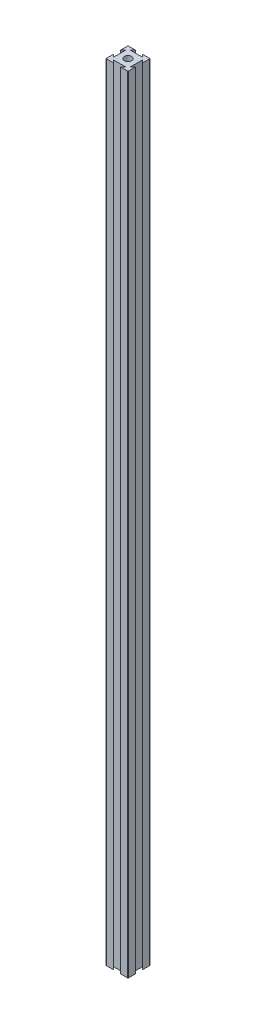
from build123d import *

# Parameters (mm, degrees)
SKETCH1_R           = 3.333333333
BOSS_EXTRUDE1_DEPTH = 711.2
FILLET4_R           = 0.508


with BuildPart() as part:
    # Sketch1 → Boss-Extrude1 (new body)
    with BuildSketch(Plane(origin=(0, 0, 0), x_dir=(1, 0, 0), z_dir=(0, 1, 0))):
        Polygon((4.285, 17.618333333), (6.666666667, 20), (0, 20), (0, 13.333333333), (2.381666667, 15.715), (2.381666667, 4.285), (0, 6.666666667), (0, 0), (6.666666667, 0), (4.285, 2.381666667), (15.715, 2.381666667), (13.333333333, 0), (20, 0), (20, 6.666666667), (17.618333333, 4.285), (17.618333333, 15.715), (20, 13.333333333), (20, 20), (13.333333333, 20), (15.715, 17.618333333), align=None)
        with Locations((10, 10)):
            Circle(SKETCH1_R, mode=Mode.SUBTRACT)
    extrude(amount=BOSS_EXTRUDE1_DEPTH)

    # Fillet4
    fillet4_edges = [part.edges().sort_by_distance(p)[0] for p in [
        (20, 355.6, 0),
        (0, 355.6, 0),
        (0, 355.6, -20),
        (20, 355.6, -20),
    ]]
    fillet(fillet4_edges, radius=FILLET4_R)


solid = part.part
